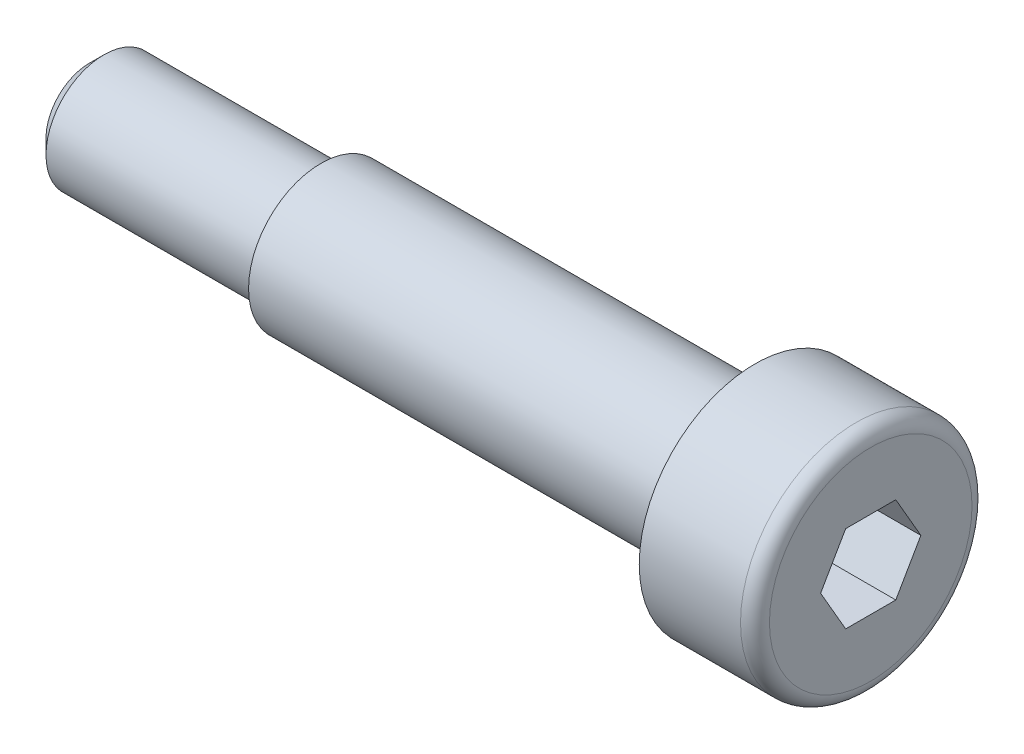
from build123d import *

# Parameters (mm, degrees)
CHAMFER1_SIZE      = 0.5
CUT_EXTRUDE1_DEPTH = 2.4


with BuildPart() as part:
    # Sketch1 → Revolve1 (revolve)
    with BuildSketch(Plane.XY):
        with BuildLine():
            Line((0, 0), (0, 3.5))
            ThreePointArc((0, 3.5), (-0.146446609, 3.853553391), (-0.5, 4))
            Line((-0.5, 4), (-4, 4))
            Line((-4, 4), (-4, 2.5))
            Line((-4, 2.5), (-19, 2.5))
            Line((-19, 2.5), (-19, 2))
            Line((-19, 2), (-27, 2))
            Line((-27, 2), (-27, 0))
            Line((-27, 0), (0, 0))
        make_face()
    revolve(axis=Axis((0, 0, 0), (1, 0, 0)))

    # Chamfer1
    chamfer1_edges = [part.edges().sort_by_distance(p)[0] for p in [
        (-27, -2, 0),
    ]]
    chamfer(chamfer1_edges, length=CHAMFER1_SIZE)

    # Sketch2 → Cut-Extrude1 (cut)
    with BuildSketch(Plane(origin=(0, 0, 0), x_dir=(0, 0, -1), z_dir=(1, 0, 0))):
        Polygon((1.732050808, 0), (0.866025404, 1.5), (-0.866025404, 1.5), (-1.732050808, 0), (-0.866025404, -1.5), (0.866025404, -1.5), align=None)
    extrude(amount=-CUT_EXTRUDE1_DEPTH, mode=Mode.SUBTRACT)


solid = part.part
